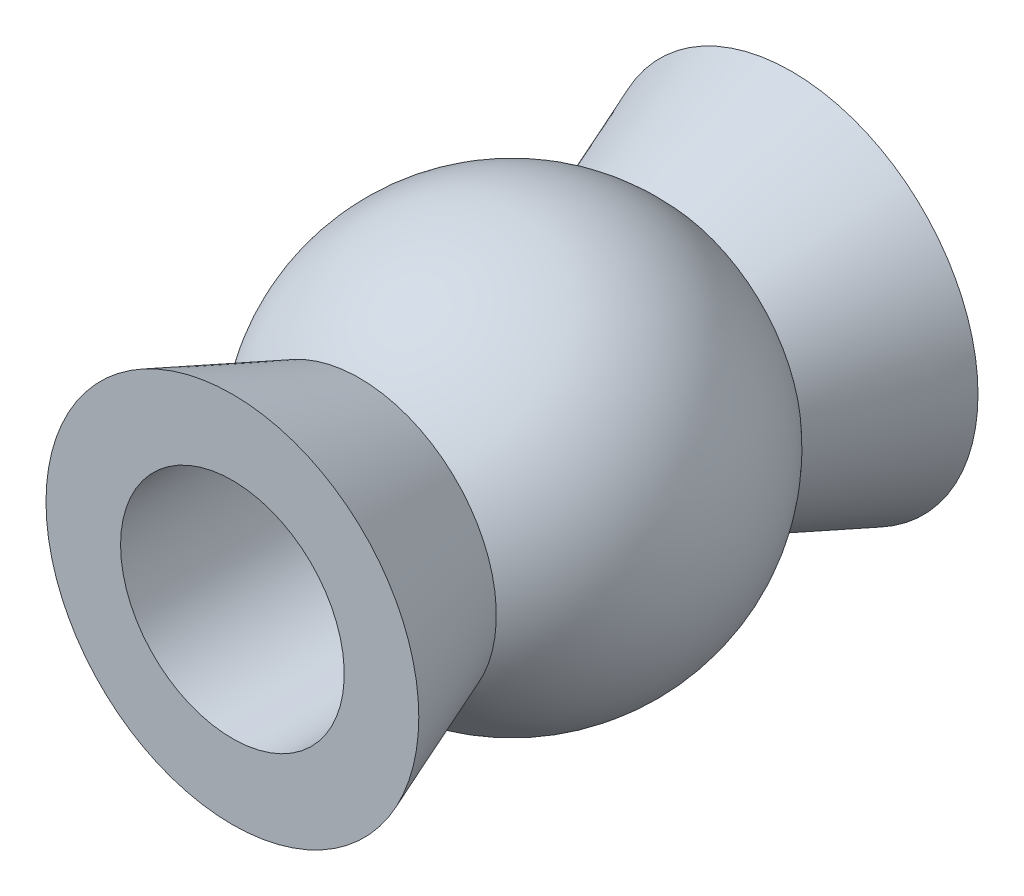
from build123d import *

# Parameters (mm, degrees)
CROQUIS5_R            = 1.5
CORTAR_EXTRUIR3_DEPTH = 10


with BuildPart() as part:
    # Croquis3 → Revolución3 (revolve)
    with BuildSketch(Plane(origin=(0, 0, 0), x_dir=(1, 0, 0), z_dir=(0, 1, 0))):
        with BuildLine():
            Line((0, 3.75), (2.5, 3.75))
            Line((2.5, 3.75), (2, 2.466364983))
            Line((2, 2.466364983), (1.836579632, 2.046820768))
            ThreePointArc((1.836579632, 2.046820768), (2.75, 0), (1.836579632, -2.046820768))
            Line((1.836579632, -2.046820768), (2, -2.466364983))
            Line((2, -2.466364983), (2.5, -3.75))
            Line((2.5, -3.75), (0, -3.75))
            Line((0, -3.75), (0, 3.75))
        make_face()
    revolve(axis=Axis((0, 0, -3.75), (0, 0, 1)))

    # Croquis5 → Cortar-Extruir3 (cut)
    with BuildSketch(Plane(origin=(0, 0, -3.75), x_dir=(-1, 0, 0), z_dir=(0, 0, -1))):
        Circle(CROQUIS5_R)
    extrude(amount=-CORTAR_EXTRUIR3_DEPTH, mode=Mode.SUBTRACT)


solid = part.part
